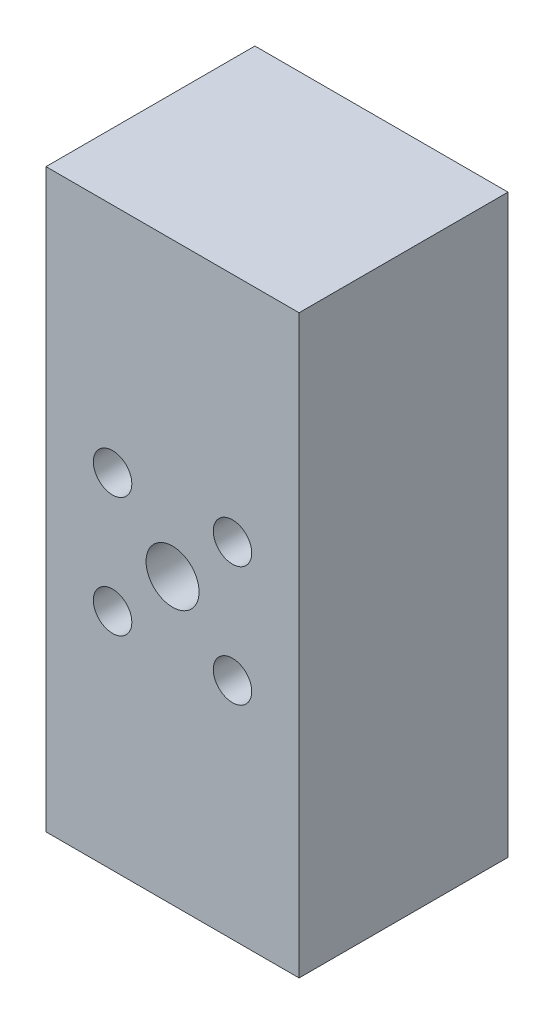
from build123d import *

# Parameters (mm, degrees)
SKETCH1_W           = 47
SKETCH1_H           = 38.8
SKETCH1_R           = 2.5
SKETCH1_R_2         = 2.627
BOSS_EXTRUDE1_DEPTH = 106.999989
SKETCH2_R           = 3.571875
SKETCH2_R_2         = 4.92125
CUT_EXTRUDE1_DEPTH  = 39.8
SKETCH1_8_R         = 2.627
SKETCH1_8_R_2       = 2.5
CUT_EXTRUDE2_DEPTH  = 38.1
CUT_EXTRUDE3_START  = -47
SKETCH3_R           = 2
CUT_EXTRUDE3_DEPTH  = 25.4
SKETCH4_R           = 9.525
CUT_EXTRUDE4_DEPTH  = 21.0185


with BuildPart() as part:
    # Sketch1 → Boss-Extrude1 (new body)
    with BuildSketch(Plane(origin=(0, 0, 0), x_dir=(1, 0, 0), z_dir=(0, 1, 0))):
        with Locations((23.5, 19.4)):
            Rectangle(SKETCH1_W, SKETCH1_H)
        with Locations((4.5, 4.4)):
            Circle(SKETCH1_R, mode=Mode.SUBTRACT)
        with Locations((42.5, 4.4)):
            Circle(SKETCH1_R, mode=Mode.SUBTRACT)
        with Locations((4.5, 34.4)):
            Circle(SKETCH1_R_2, mode=Mode.SUBTRACT)
        with Locations((42.5, 34.4)):
            Circle(SKETCH1_R, mode=Mode.SUBTRACT)
        with Locations((42.5, 4.4)):
            Circle(SKETCH1_R)
        with Locations((4.5, 4.4)):
            Circle(SKETCH1_R)
        with Locations((4.5, 34.4)):
            Circle(SKETCH1_R_2)
        with Locations((42.5, 34.4)):
            Circle(SKETCH1_R)
    extrude(amount=BOSS_EXTRUDE1_DEPTH)

    # Sketch2 → Cut-Extrude1 (cut, through all)
    with BuildSketch(Plane.XY):
        with Locations((12.36448241, 63.94291018)):
            Circle(SKETCH2_R)
        with Locations((34.63551759, 63.94291018)):
            Circle(SKETCH2_R)
        with Locations((34.63551759, 41.671875)):
            Circle(SKETCH2_R)
        with Locations((23.5, 52.80739259)):
            Circle(SKETCH2_R_2)
        with Locations((12.36448241, 41.671875)):
            Circle(SKETCH2_R)
    extrude(amount=-CUT_EXTRUDE1_DEPTH, mode=Mode.SUBTRACT)

    # Sketch1_8 → Cut-Extrude2 (cut)
    with BuildSketch(Plane(origin=(0, 0, 0), x_dir=(1, 0, 0), z_dir=(0, 1, 0))):
        with Locations((4.5, 34.4)):
            Circle(SKETCH1_8_R)
        with Locations((4.5, 4.4)):
            Circle(SKETCH1_8_R_2)
        with Locations((42.5, 4.4)):
            Circle(SKETCH1_8_R_2)
        with Locations((42.5, 34.4)):
            Circle(SKETCH1_8_R_2)
    extrude(amount=CUT_EXTRUDE2_DEPTH, mode=Mode.SUBTRACT)

    # Sketch3 → Cut-Extrude3 (cut)
    with BuildSketch(Plane(origin=(47, 0, 0), x_dir=(0, 0, -1), z_dir=(1, 0, 0)).offset(CUT_EXTRUDE3_START)):
        with Locations((19.4, 20)):
            Circle(SKETCH3_R)
        with Locations((19.4, 79.944)):
            Circle(SKETCH3_R)
    extrude(amount=CUT_EXTRUDE3_DEPTH, mode=Mode.SUBTRACT)

    # Sketch4 → Cut-Extrude4 (cut)
    with BuildSketch(Plane(origin=(0, 0, -38.8), x_dir=(-1, 0, 0), z_dir=(0, 0, -1))):
        with Locations((-23.5, 52.80739259)):
            Circle(SKETCH4_R)
    extrude(amount=-CUT_EXTRUDE4_DEPTH, mode=Mode.SUBTRACT)


solid = part.part
